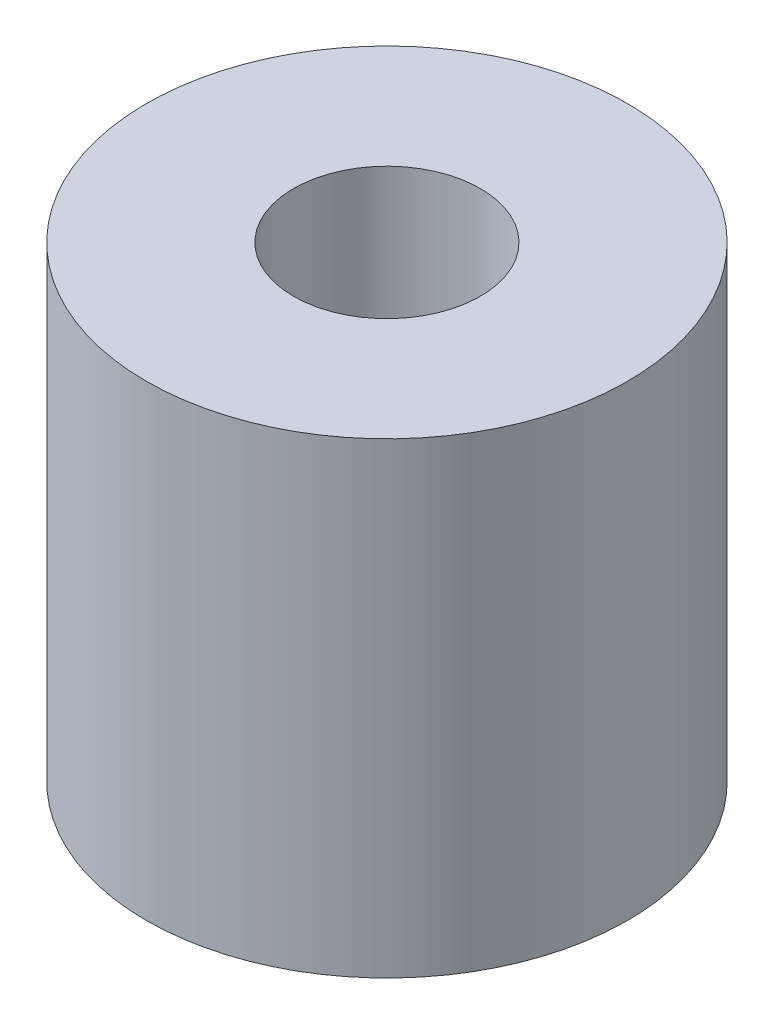
from build123d import *

# Parameters (mm, degrees)
SKETCH2_R           = 8.5
SKETCH2_R_2         = 3.3
BOSS_EXTRUDE1_DEPTH = 2
BOSS_EXTRUDE2_START = -5.5
SKETCH2_4_R         = 8.5
BOSS_EXTRUDE2_DEPTH = 5.5
SKETCH3_R           = 8.5
SKETCH3_R_2         = 3.3
BOSS_EXTRUDE3_DEPTH = 9


with BuildPart() as part:
    # Sketch2 → Boss-Extrude1 (new body)
    with BuildSketch(Plane(origin=(0, 0, 0), x_dir=(1, 0, 0), z_dir=(0, 1, 0))):
        Circle(SKETCH2_R)
        Circle(SKETCH2_R_2, mode=Mode.SUBTRACT)
    extrude(amount=BOSS_EXTRUDE1_DEPTH)

    # Sketch2_4 → Boss-Extrude2 (add)
    with BuildSketch(Plane(origin=(0, 0, 0), x_dir=(1, 0, 0), z_dir=(0, 1, 0)).offset(BOSS_EXTRUDE2_START)):
        Circle(SKETCH2_4_R)
        Polygon((-3.204293994, -5.55), (-6.408587988, 0), (-3.204293994, 5.55), (3.204293994, 5.55), (6.408587988, 0), (3.204293994, -5.55), align=None, mode=Mode.SUBTRACT)
    extrude(amount=BOSS_EXTRUDE2_DEPTH)

    # Sketch3 → Boss-Extrude3 (add)
    with BuildSketch(Plane(origin=(0, 2, 0), x_dir=(1, 0, 0), z_dir=(0, 1, 0))):
        Circle(SKETCH3_R)
        Circle(SKETCH3_R_2, mode=Mode.SUBTRACT)
    extrude(amount=BOSS_EXTRUDE3_DEPTH)


solid = part.part
